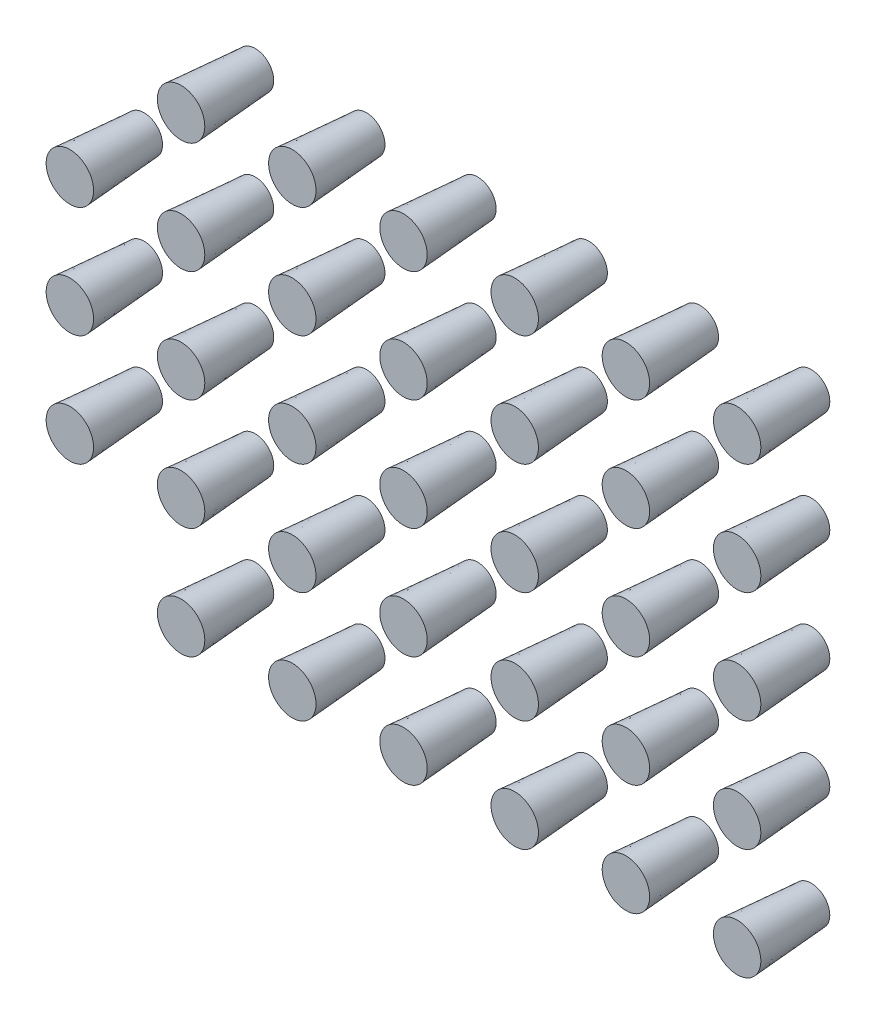
from build123d import *

# Parameters (mm, degrees)
SKETCH_1_R               = 0.5
EXTRUDE_1_DEPTH          = 2
EXTRUDE_1_TAPER          = -4
PATTERN_LINEAR_1_COUNT   = 6
PATTERN_LINEAR_1_PITCH   = 3
PATTERN_LINEAR_1_2_COUNT = 6
PATTERN_LINEAR_1_2_PITCH = 3
PATTERN_LINEAR_2_COUNT   = 2
PATTERN_LINEAR_2_PITCH   = 3
PATTERN_LINEAR_3_COUNT   = 2
PATTERN_LINEAR_3_PITCH   = 3


with BuildPart() as part:
    # 草图1 → 凸台-拉伸1 (new body)
    with BuildSketch(Plane.XY):
        Circle(SKETCH_1_R)
    extrude(amount=EXTRUDE_1_DEPTH, taper=EXTRUDE_1_TAPER)


with BuildPart() as pattern_linear_1_1:
    # 阵列(线性)1: pattern copy
    add(part.part.moved(Location(Vector(0, 1, 0) * (1 * PATTERN_LINEAR_1_PITCH))))


with BuildPart() as pattern_linear_1_2:
    # 阵列(线性)1: pattern copy
    add(part.part.moved(Location(Vector(0, 1, 0) * (2 * PATTERN_LINEAR_1_PITCH))))


with BuildPart() as pattern_linear_1_3:
    # 阵列(线性)1: pattern copy
    add(part.part.moved(Location(Vector(0, 1, 0) * (3 * PATTERN_LINEAR_1_PITCH))))


with BuildPart() as pattern_linear_1_4:
    # 阵列(线性)1: pattern copy
    add(part.part.moved(Location(Vector(0, 1, 0) * (4 * PATTERN_LINEAR_1_PITCH))))


with BuildPart() as pattern_linear_1_5:
    # 阵列(线性)1: pattern copy
    add(part.part.moved(Location(Vector(0, 1, 0) * (5 * PATTERN_LINEAR_1_PITCH))))


with BuildPart() as pattern_linear_1_2_1:
    # Pattern Linear 1 2: pattern copy
    add(part.part.moved(Location(Vector(1, 0, 0) * (1 * PATTERN_LINEAR_1_2_PITCH))))


with BuildPart() as pattern_linear_1_2_2:
    # Pattern Linear 1 2: pattern copy
    add(part.part.moved(Location(Vector(1, 0, 0) * (2 * PATTERN_LINEAR_1_2_PITCH))))


with BuildPart() as pattern_linear_1_2_3:
    # Pattern Linear 1 2: pattern copy
    add(part.part.moved(Location(Vector(1, 0, 0) * (3 * PATTERN_LINEAR_1_2_PITCH))))


with BuildPart() as pattern_linear_1_2_4:
    # Pattern Linear 1 2: pattern copy
    add(part.part.moved(Location(Vector(1, 0, 0) * (4 * PATTERN_LINEAR_1_2_PITCH))))


with BuildPart() as pattern_linear_1_2_5:
    # Pattern Linear 1 2: pattern copy
    add(part.part.moved(Location(Vector(1, 0, 0) * (5 * PATTERN_LINEAR_1_2_PITCH))))


with BuildPart() as pattern_linear_1_2_6:
    # Pattern Linear 1 2: pattern copy
    add(pattern_linear_1_1.part.moved(Location(Vector(1, 0, 0) * (1 * PATTERN_LINEAR_1_2_PITCH))))


with BuildPart() as pattern_linear_1_2_7:
    # Pattern Linear 1 2: pattern copy
    add(pattern_linear_1_1.part.moved(Location(Vector(1, 0, 0) * (2 * PATTERN_LINEAR_1_2_PITCH))))


with BuildPart() as pattern_linear_1_2_8:
    # Pattern Linear 1 2: pattern copy
    add(pattern_linear_1_1.part.moved(Location(Vector(1, 0, 0) * (3 * PATTERN_LINEAR_1_2_PITCH))))


with BuildPart() as pattern_linear_1_2_9:
    # Pattern Linear 1 2: pattern copy
    add(pattern_linear_1_1.part.moved(Location(Vector(1, 0, 0) * (4 * PATTERN_LINEAR_1_2_PITCH))))


with BuildPart() as pattern_linear_1_2_10:
    # Pattern Linear 1 2: pattern copy
    add(pattern_linear_1_1.part.moved(Location(Vector(1, 0, 0) * (5 * PATTERN_LINEAR_1_2_PITCH))))


with BuildPart() as pattern_linear_1_2_11:
    # Pattern Linear 1 2: pattern copy
    add(pattern_linear_1_2.part.moved(Location(Vector(1, 0, 0) * (1 * PATTERN_LINEAR_1_2_PITCH))))


with BuildPart() as pattern_linear_1_2_12:
    # Pattern Linear 1 2: pattern copy
    add(pattern_linear_1_2.part.moved(Location(Vector(1, 0, 0) * (2 * PATTERN_LINEAR_1_2_PITCH))))


with BuildPart() as pattern_linear_1_2_13:
    # Pattern Linear 1 2: pattern copy
    add(pattern_linear_1_2.part.moved(Location(Vector(1, 0, 0) * (3 * PATTERN_LINEAR_1_2_PITCH))))


with BuildPart() as pattern_linear_1_2_14:
    # Pattern Linear 1 2: pattern copy
    add(pattern_linear_1_2.part.moved(Location(Vector(1, 0, 0) * (4 * PATTERN_LINEAR_1_2_PITCH))))


with BuildPart() as pattern_linear_1_2_15:
    # Pattern Linear 1 2: pattern copy
    add(pattern_linear_1_2.part.moved(Location(Vector(1, 0, 0) * (5 * PATTERN_LINEAR_1_2_PITCH))))


with BuildPart() as pattern_linear_1_2_16:
    # Pattern Linear 1 2: pattern copy
    add(pattern_linear_1_3.part.moved(Location(Vector(1, 0, 0) * (1 * PATTERN_LINEAR_1_2_PITCH))))


with BuildPart() as pattern_linear_1_2_17:
    # Pattern Linear 1 2: pattern copy
    add(pattern_linear_1_3.part.moved(Location(Vector(1, 0, 0) * (2 * PATTERN_LINEAR_1_2_PITCH))))


with BuildPart() as pattern_linear_1_2_18:
    # Pattern Linear 1 2: pattern copy
    add(pattern_linear_1_3.part.moved(Location(Vector(1, 0, 0) * (3 * PATTERN_LINEAR_1_2_PITCH))))


with BuildPart() as pattern_linear_1_2_19:
    # Pattern Linear 1 2: pattern copy
    add(pattern_linear_1_3.part.moved(Location(Vector(1, 0, 0) * (4 * PATTERN_LINEAR_1_2_PITCH))))


with BuildPart() as pattern_linear_1_2_20:
    # Pattern Linear 1 2: pattern copy
    add(pattern_linear_1_3.part.moved(Location(Vector(1, 0, 0) * (5 * PATTERN_LINEAR_1_2_PITCH))))


with BuildPart() as pattern_linear_1_2_21:
    # Pattern Linear 1 2: pattern copy
    add(pattern_linear_1_4.part.moved(Location(Vector(1, 0, 0) * (1 * PATTERN_LINEAR_1_2_PITCH))))


with BuildPart() as pattern_linear_1_2_22:
    # Pattern Linear 1 2: pattern copy
    add(pattern_linear_1_4.part.moved(Location(Vector(1, 0, 0) * (2 * PATTERN_LINEAR_1_2_PITCH))))


with BuildPart() as pattern_linear_1_2_23:
    # Pattern Linear 1 2: pattern copy
    add(pattern_linear_1_4.part.moved(Location(Vector(1, 0, 0) * (3 * PATTERN_LINEAR_1_2_PITCH))))


with BuildPart() as pattern_linear_1_2_24:
    # Pattern Linear 1 2: pattern copy
    add(pattern_linear_1_4.part.moved(Location(Vector(1, 0, 0) * (4 * PATTERN_LINEAR_1_2_PITCH))))


with BuildPart() as pattern_linear_1_2_25:
    # Pattern Linear 1 2: pattern copy
    add(pattern_linear_1_4.part.moved(Location(Vector(1, 0, 0) * (5 * PATTERN_LINEAR_1_2_PITCH))))


with BuildPart() as pattern_linear_1_2_26:
    # Pattern Linear 1 2: pattern copy
    add(pattern_linear_1_5.part.moved(Location(Vector(1, 0, 0) * (1 * PATTERN_LINEAR_1_2_PITCH))))


with BuildPart() as pattern_linear_1_2_27:
    # Pattern Linear 1 2: pattern copy
    add(pattern_linear_1_5.part.moved(Location(Vector(1, 0, 0) * (2 * PATTERN_LINEAR_1_2_PITCH))))


with BuildPart() as pattern_linear_1_2_28:
    # Pattern Linear 1 2: pattern copy
    add(pattern_linear_1_5.part.moved(Location(Vector(1, 0, 0) * (3 * PATTERN_LINEAR_1_2_PITCH))))


with BuildPart() as pattern_linear_1_2_29:
    # Pattern Linear 1 2: pattern copy
    add(pattern_linear_1_5.part.moved(Location(Vector(1, 0, 0) * (4 * PATTERN_LINEAR_1_2_PITCH))))


with BuildPart() as pattern_linear_1_2_30:
    # Pattern Linear 1 2: pattern copy
    add(pattern_linear_1_5.part.moved(Location(Vector(1, 0, 0) * (5 * PATTERN_LINEAR_1_2_PITCH))))


with BuildPart() as pattern_linear_2_1:
    # 阵列(线性)2: pattern copy
    add(pattern_linear_1_4.part.moved(Location(Vector(-1, 0, 0) * (1 * PATTERN_LINEAR_2_PITCH))))


with BuildPart() as pattern_linear_2_2:
    # 阵列(线性)2: pattern copy
    add(pattern_linear_1_3.part.moved(Location(Vector(-1, 0, 0) * (1 * PATTERN_LINEAR_2_PITCH))))


with BuildPart() as pattern_linear_2_3:
    # 阵列(线性)2: pattern copy
    add(pattern_linear_1_2.part.moved(Location(Vector(-1, 0, 0) * (1 * PATTERN_LINEAR_2_PITCH))))


with BuildPart() as pattern_linear_2_4:
    # 阵列(线性)2: pattern copy
    add(pattern_linear_1_1.part.moved(Location(Vector(-1, 0, 0) * (1 * PATTERN_LINEAR_2_PITCH))))


with BuildPart() as pattern_linear_3_1:
    # 阵列(线性)3: pattern copy
    add(pattern_linear_2_2.part.moved(Location(Vector(-1, 0, 0) * (1 * PATTERN_LINEAR_3_PITCH))))


with BuildPart() as pattern_linear_3_2:
    # 阵列(线性)3: pattern copy
    add(pattern_linear_2_3.part.moved(Location(Vector(-1, 0, 0) * (1 * PATTERN_LINEAR_3_PITCH))))


solid = Compound([part.part, pattern_linear_1_1.part, pattern_linear_1_2.part, pattern_linear_1_3.part, pattern_linear_1_4.part, pattern_linear_1_2_1.part, pattern_linear_1_2_2.part, pattern_linear_1_2_3.part, pattern_linear_1_2_4.part, pattern_linear_1_2_5.part, pattern_linear_1_2_6.part, pattern_linear_1_2_7.part, pattern_linear_1_2_8.part, pattern_linear_1_2_9.part, pattern_linear_1_2_10.part, pattern_linear_1_2_11.part, pattern_linear_1_2_12.part, pattern_linear_1_2_13.part, pattern_linear_1_2_14.part, pattern_linear_1_2_15.part, pattern_linear_1_2_16.part, pattern_linear_1_2_17.part, pattern_linear_1_2_18.part, pattern_linear_1_2_19.part, pattern_linear_1_2_20.part, pattern_linear_1_2_21.part, pattern_linear_1_2_22.part, pattern_linear_1_2_23.part, pattern_linear_1_2_24.part, pattern_linear_1_2_25.part, pattern_linear_2_2.part, pattern_linear_2_3.part, pattern_linear_2_4.part])
